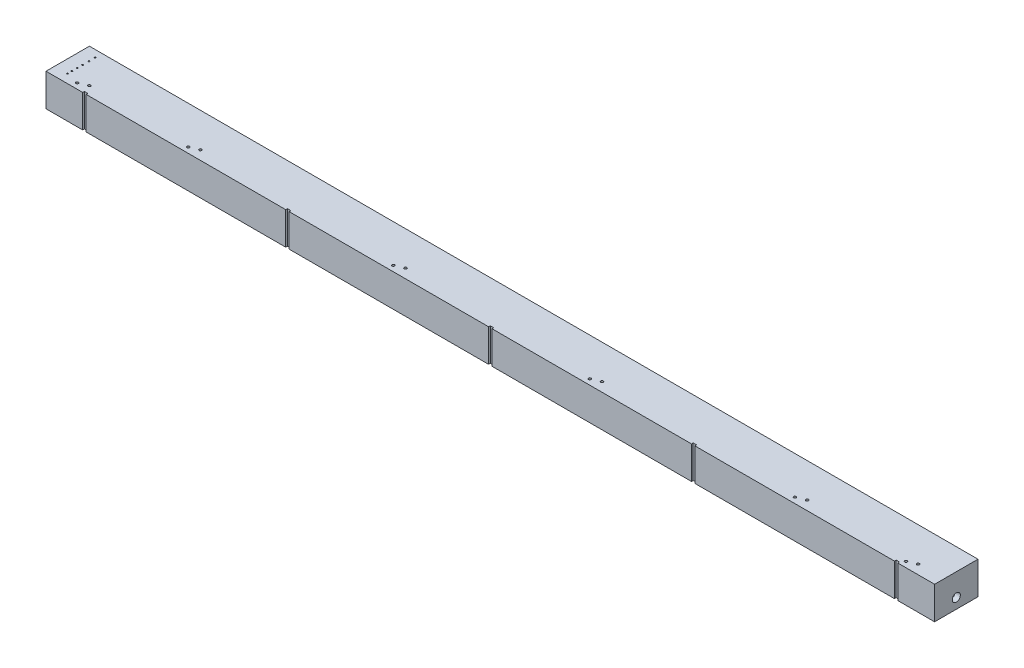
from build123d import *

# Parameters (mm, degrees)
SKETCH1_W           = 1040
SKETCH1_H           = 50.8
BOSS_EXTRUDE1_DEPTH = 38.1
SKETCH7_R           = 1.5
CUT_EXTRUDE14_DEPTH = 5
CUT_EXTRUDE15_DEPTH = 10
CUT_EXTRUDE16_DEPTH = 4.7625
SKETCH2_W           = 4
SKETCH2_H           = 2
CUT_EXTRUDE18_DEPTH = 39.1
HOLE2_AT_2_COUNT    = 2
HOLE2_AT_2_PITCH    = 7.294
HOLE2_AT_3_COUNT    = 2
HOLE2_AT_3_PITCH    = 14.588
HOLE2_AT_4_COUNT    = 2
HOLE2_AT_4_PITCH    = 20.948
HOLE2_AT_5_COUNT    = 2
HOLE2_AT_5_PITCH    = 27.308
HOLE2_AT_6_COUNT    = 2
HOLE2_AT_6_PITCH    = 32.42


with BuildPart() as part:
    # Sketch1 → Boss-Extrude1 (new body)
    with BuildSketch(Plane(origin=(0, 0, 0), x_dir=(1, 0, 0), z_dir=(0, 1, 0))):
        with Locations((520, 25.4)):
            Rectangle(SKETCH1_W, SKETCH1_H)
    extrude(amount=BOSS_EXTRUDE1_DEPTH)

    # Sketch7 → Cut-Extrude14 (cut)
    with BuildSketch(Plane(origin=(0, 38.1, 0), x_dir=(1, 0, 0), z_dir=(0, 1, 0))):
        with Locations(Location((400, 6.513, 0), (0, 0, 270))):  # turned: the seam where the file's is
            Circle(SKETCH7_R)
        with Locations(Location((160, 6.513, 0), (0, 0, 270))):  # turned: the seam where the file's is
            Circle(SKETCH7_R)
        with Locations(Location((870, 6.513, 0), (0, 0, 270))):  # turned: the seam where the file's is
            Circle(SKETCH7_R)
        with Locations(Location((630, 6.513, 0), (0, 0, 270))):  # turned: the seam where the file's is
            Circle(SKETCH7_R)
        with Locations(Location((170, 10.725, 0), (0, 0, 270))):  # turned: the seam where the file's is
            Circle(SKETCH7_R)
        with Locations(Location((30, 6.513, 0), (0, 0, 270))):  # turned: the seam where the file's is
            Circle(SKETCH7_R)
        with Locations(Location((40, 10.725, 0), (0, 0, 270))):  # turned: the seam where the file's is
            Circle(SKETCH7_R)
        with Locations(Location((1000, 6.513, 0), (0, 0, 270))):  # turned: the seam where the file's is
            Circle(SKETCH7_R)
        with Locations(Location((410, 10.725, 0), (0, 0, 270))):  # turned: the seam where the file's is
            Circle(SKETCH7_R)
        with Locations(Location((1010, 10.725, 0), (0, 0, 270))):  # turned: the seam where the file's is
            Circle(SKETCH7_R)
        with Locations(Location((640, 10.725, 0), (0, 0, 270))):  # turned: the seam where the file's is
            Circle(SKETCH7_R)
        with Locations(Location((880, 10.725, 0), (0, 0, 270))):  # turned: the seam where the file's is
            Circle(SKETCH7_R)
    extrude(amount=-CUT_EXTRUDE14_DEPTH, mode=Mode.SUBTRACT)

    # Sketch8 → Cut-Extrude15 (cut)
    with BuildSketch(Plane.XZ):
        with BuildLine():
            Line((12, -44.8), (1028, -44.8))
            ThreePointArc((1028, -44.8), (1032.242640687, -43.042640687), (1034, -38.8))
            Line((1034, -38.8), (1034, -12))
            ThreePointArc((1034, -12), (1032.242640687, -7.757359313), (1028, -6))
            Line((1028, -6), (12, -6))
            ThreePointArc((12, -6), (7.757359313, -7.757359313), (6, -12))
            Line((6, -12), (6, -38.8))
            ThreePointArc((6, -38.8), (7.757359313, -43.042640687), (12, -44.8))
        make_face()
    extrude(amount=-CUT_EXTRUDE15_DEPTH, mode=Mode.SUBTRACT)

    # Sketch8_3 → Cut-Extrude16 (cut)
    with BuildSketch(Plane.XZ):
        with BuildLine():
            Line((9, -47.8), (1031, -47.8))
            ThreePointArc((1031, -47.8), (1035.242640687, -46.042640687), (1037, -41.8))
            Line((1037, -41.8), (1037, -9))
            ThreePointArc((1037, -9), (1035.242640687, -4.757359313), (1031, -3))
            Line((1031, -3), (9, -3))
            ThreePointArc((9, -3), (4.757359313, -4.757359313), (3, -9))
            Line((3, -9), (3, -41.8))
            ThreePointArc((3, -41.8), (4.757359313, -46.042640687), (9, -47.8))
        make_face()
    extrude(amount=-CUT_EXTRUDE16_DEPTH, mode=Mode.SUBTRACT)

    # Sketch2 → Cut-Extrude18 (cut, through all)
    with BuildSketch(Plane(origin=(0, 38.1, 0), x_dir=(1, 0, 0), z_dir=(0, 1, 0))):
        with Locations((45, 1)):
            Rectangle(SKETCH2_W, SKETCH2_H)
        with Locations((282.5, 1)):
            Rectangle(SKETCH2_W, SKETCH2_H)
        with Locations((520, 1)):
            Rectangle(SKETCH2_W, SKETCH2_H)
        with Locations((757.5, 1)):
            Rectangle(SKETCH2_W, SKETCH2_H)
        with Locations((995, 1)):
            Rectangle(SKETCH2_W, SKETCH2_H)
    extrude(amount=-CUT_EXTRUDE18_DEPTH, mode=Mode.SUBTRACT)

    # Sketch12 → 1_8 NPT Tapped Hole2 (revolve, cut)
    with BuildSketch(Plane(origin=(1040, 12, -25.4), x_dir=(0, 0, -1), z_dir=(0, 1, 0))):
        Polygon((0, 0), (0, 27.533468714), (4.2164, 25), (4.2164, 6.92), (4.537398933, 6.92), (4.744593, 0), align=None)
    revolve(axis=Axis((1046.35, 12, -25.4), (-1, 0, 0)), mode=Mode.SUBTRACT)

    # Sketch14 → 1_8 NPT Tapped Hole3 (revolve, cut)
    with BuildSketch(Plane(origin=(0, 12, -25.4), x_dir=(0, 0, 1), z_dir=(0, 1, 0))):
        Polygon((0, 0), (0, 27.533468714), (4.2164, 25), (4.2164, 6.92), (4.537398933, 6.92), (4.744593, 0), align=None)
    revolve(axis=Axis((-6.35, 12, -25.4), (1, 0, 0)), mode=Mode.SUBTRACT)

    # Sketch26 → Hole2 (revolve, cut)
    with BuildSketch(Plane(origin=(15, 10, -42.533), x_dir=(0, 0, -1), z_dir=(1, 0, 0))):
        Polygon((0, 0), (0, 28.1), (0.79375, 28.1), (0.79375, 20.953866233), (2.38125, 20), (2.38125, 0), align=None)
    hole2 = revolve(axis=Axis((15, 3.869976101, -42.533), (0, 1, 0)), mode=Mode.SUBTRACT)

    # Hole2 at 2: Hole2 ×2
    with Locations(*[(0, 0, i * HOLE2_AT_2_PITCH) for i in range(1, HOLE2_AT_2_COUNT)]):
        add(hole2, mode=Mode.SUBTRACT)

    # Hole2 at 3: Hole2 ×2
    with Locations(*[(0, 0, i * HOLE2_AT_3_PITCH) for i in range(1, HOLE2_AT_3_COUNT)]):
        add(hole2, mode=Mode.SUBTRACT)

    # Hole2 at 4: Hole2 ×2
    with Locations(*[(0, 0, i * HOLE2_AT_4_PITCH) for i in range(1, HOLE2_AT_4_COUNT)]):
        add(hole2, mode=Mode.SUBTRACT)

    # Hole2 at 5: Hole2 ×2
    with Locations(*[(0, 0, i * HOLE2_AT_5_PITCH) for i in range(1, HOLE2_AT_5_COUNT)]):
        add(hole2, mode=Mode.SUBTRACT)

    # Hole2 at 6: Hole2 ×2
    with Locations(*[(0, 0, i * HOLE2_AT_6_PITCH) for i in range(1, HOLE2_AT_6_COUNT)]):
        add(hole2, mode=Mode.SUBTRACT)


solid = part.part
